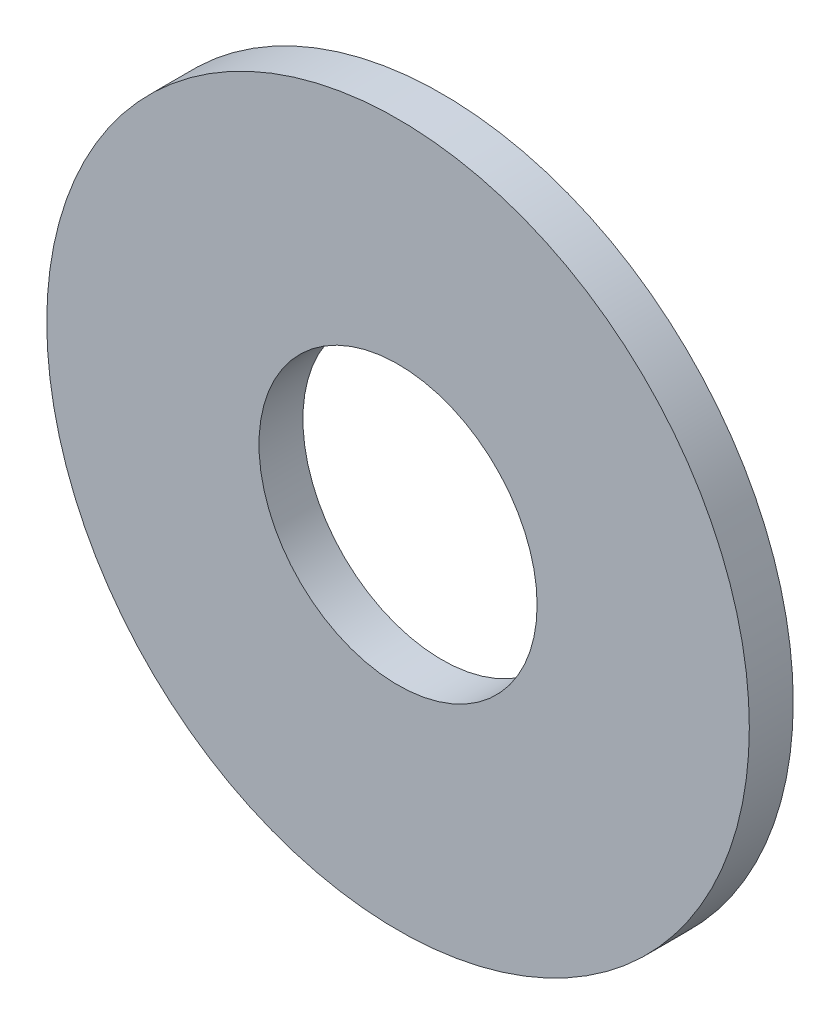
from build123d import *

# Parameters (mm, degrees)
SKETCH1_R           = 24
BOSS_EXTRUDE1_DEPTH = 3
CUT_EXTRUDE1_REACH  = 5
SKETCH2_R           = 9.5


with BuildPart() as part:
    # Sketch1 → Boss-Extrude1 (new body)
    with BuildSketch(Plane.XY):
        Circle(SKETCH1_R)
    extrude(amount=-BOSS_EXTRUDE1_DEPTH)

    # Sketch2 → Cut-Extrude1 (cut, up to next)
    with BuildSketch(Plane.XY, mode=Mode.PRIVATE) as cut_extrude1_sk1:
        Circle(SKETCH2_R)
    cut_extrude1_tool1 = extrude(cut_extrude1_sk1.sketch, amount=-CUT_EXTRUDE1_REACH, mode=Mode.PRIVATE) & part.part
    add(cut_extrude1_tool1.solids().sort_by_distance((0, 0, 0))[0], mode=Mode.SUBTRACT)


solid = part.part
